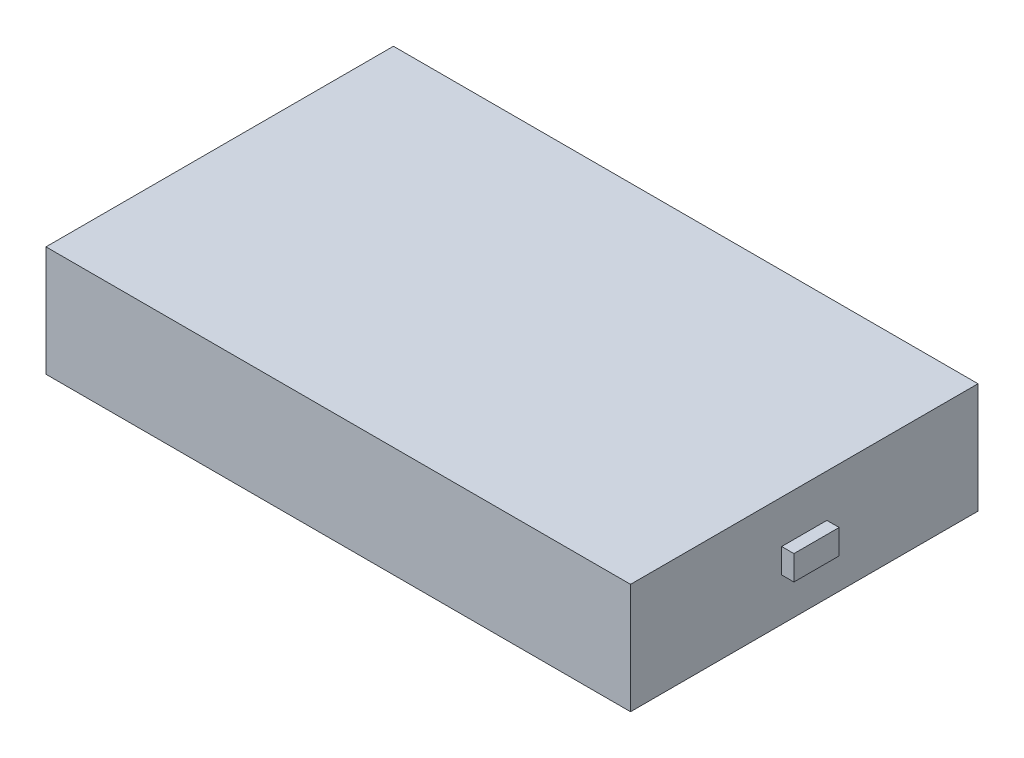
from build123d import *

# Parameters (mm, degrees)
SKETCH1_W           = 143
SKETCH1_H           = 85
BOSS_EXTRUDE1_DEPTH = 27
SKETCH2_W           = 11.06520749
SKETCH2_H           = 6.024390745
BOSS_EXTRUDE2_DEPTH = 3


with BuildPart() as part:
    # Sketch1 → Boss-Extrude1 (new body)
    with BuildSketch(Plane(origin=(0, 0, 0), x_dir=(1, 0, 0), z_dir=(0, 1, 0))):
        Rectangle(SKETCH1_W, SKETCH1_H)
    extrude(amount=BOSS_EXTRUDE1_DEPTH)

    # Sketch2 → Boss-Extrude2 (add)
    with BuildSketch(Plane(origin=(71.5, 0, 0), x_dir=(0, 0, -1), z_dir=(1, 0, 0))):
        with Locations((0, 13.517277192)):
            Rectangle(SKETCH2_W, SKETCH2_H)
    extrude(amount=BOSS_EXTRUDE2_DEPTH)


solid = part.part
